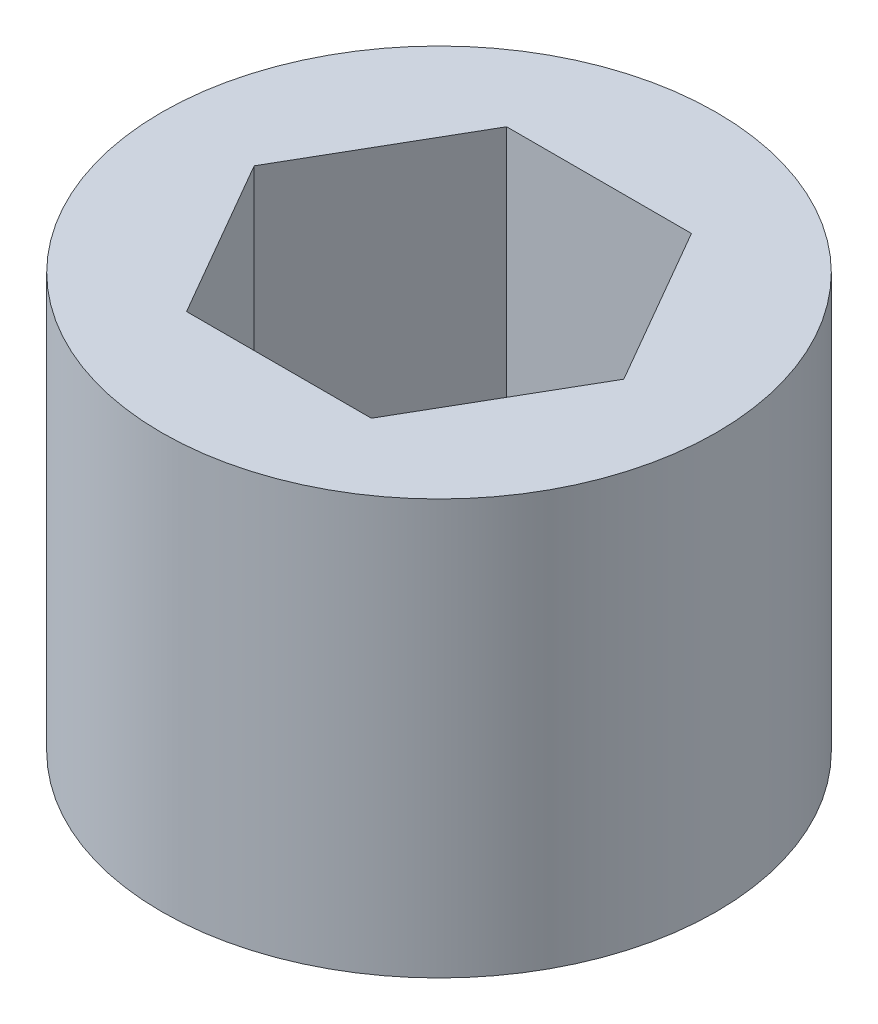
from build123d import *

# Parameters (mm, degrees)
SKETCH1_R           = 4.1275
BOSS_EXTRUDE1_DEPTH = 3.0861


with BuildPart() as part:
    # Sketch1 → Boss-Extrude1 (new body, symmetric)
    with BuildSketch(Plane(origin=(0, 0, 0), x_dir=(1, 0, 0), z_dir=(0, 1, 0))):
        Circle(SKETCH1_R)
        Polygon((1.374815329, -2.38125), (2.749630657, 0), (1.374815329, 2.38125), (-1.374815329, 2.38125), (-2.749630657, 0), (-1.374815329, -2.38125), align=None, mode=Mode.SUBTRACT)
    extrude(amount=BOSS_EXTRUDE1_DEPTH, both=True)


solid = part.part
